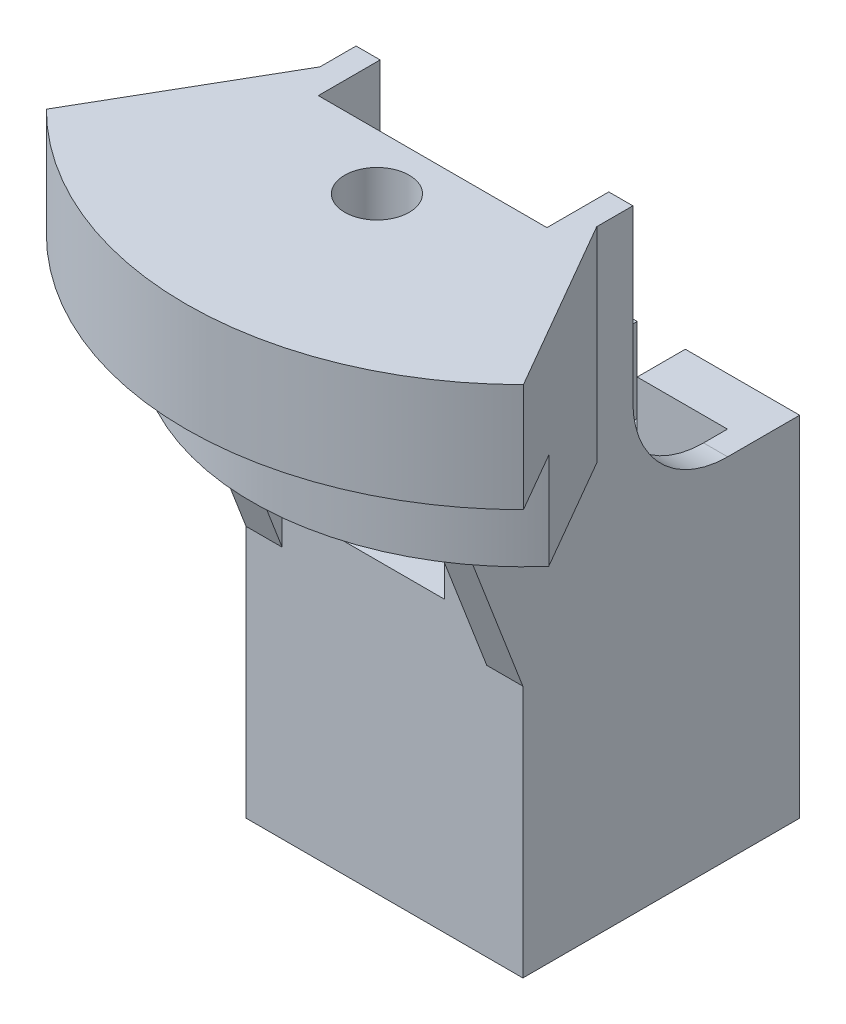
from build123d import *

# Parameters (mm, degrees)
SKETCH1_W                = 29.21
SKETCH1_H                = 29.21
BOSS_EXTRUDE1_DEPTH      = 41.91
SKETCH2_W                = 14.732
SKETCH2_H                = 14.732
CUT_EXTRUDE1_DEPTH       = 8.255
SKETCH3_W                = 24.13
SKETCH3_H                = 19.05
CUT_EXTRUDE2_DEPTH       = 33.655
SKETCH6_W                = 4.699
SKETCH6_H                = 4.445
CUT_EXTRUDE3_DEPTH       = 4.445
BOSS_EXTRUDE2_DEPTH      = 27.94
FILLET1_R                = 10
CHAMFER2_SIZE            = 5.08
CUT_EXTRUDE4_DEPTH       = 27.94
CUT_EXTRUDE5_DEPTH       = 16.51
BOSS_EXTRUDE3_DEPTH      = 10.16
M6_CLEARANCE_HOLE1_D     = 6.8032
M6_CLEARANCE_HOLE1_DEPTH = 32.5000112
M6_CLEARANCE_HOLE1_TIP   = 2.043887482
SKETCH18_W               = 12.7
SKETCH18_H               = 16.067158518
CUT_EXTRUDE9_DEPTH       = 12.7
BOSS_EXTRUDE4_DEPTH      = 3.81
SKETCH19_W               = 5.08
SKETCH19_H               = 5.08
CUT_EXTRUDE10_DEPTH      = 8.89


with BuildPart() as part:
    # Sketch1 → Boss-Extrude1 (new body)
    with BuildSketch(Plane(origin=(0, 0, 0), x_dir=(1, 0, 0), z_dir=(0, 1, 0))):
        Rectangle(SKETCH1_W, SKETCH1_H)
    extrude(amount=BOSS_EXTRUDE1_DEPTH)

    # Sketch2 → Cut-Extrude1 (cut)
    with BuildSketch(Plane.XZ):
        Rectangle(SKETCH2_W, SKETCH2_H)
    extrude(amount=-CUT_EXTRUDE1_DEPTH, mode=Mode.SUBTRACT)

    # Sketch3 → Cut-Extrude2 (cut)
    with BuildSketch(Plane.XZ.offset(-8.255)):
        Rectangle(SKETCH3_W, SKETCH3_H)
    extrude(amount=-CUT_EXTRUDE2_DEPTH, mode=Mode.SUBTRACT)

    # Sketch6 → Cut-Extrude3 (cut)
    with BuildSketch(Plane(origin=(0, 8.255, 0), x_dir=(1, 0, 0), z_dir=(0, 1, 0))):
        with Locations((-9.7155, 0)):
            Rectangle(SKETCH6_W, SKETCH6_H)
    cut_extrude3 = extrude(amount=-CUT_EXTRUDE3_DEPTH, mode=Mode.SUBTRACT)

    # Mirror1: Cut-Extrude3 across plane
    add(cut_extrude3.mirror(Plane(origin=(0, 0, 0), x_dir=(0, 0, 1), z_dir=(1, 0, 0))), mode=Mode.SUBTRACT)

    # Sketch7 → Boss-Extrude2 (add)
    with BuildSketch(Plane(origin=(0, 41.91, 0), x_dir=(1, 0, 0), z_dir=(0, 1, 0))):
        with BuildLine():
            Line((-14.605, -2.997916359), (-35.433403696, -2.997916359))
            ThreePointArc((-35.433403696, -2.997916359), (0, -35.56), (35.433403696, -2.997916359))
            Line((35.433403696, -2.997916359), (14.605, -2.997916359))
            Line((14.605, -2.997916359), (14.605, -14.605))
            Line((14.605, -14.605), (-14.605, -14.605))
            Line((-14.605, -14.605), (-14.605, -2.997916359))
        make_face()
        Polygon((-12.065, -2.997916359), (-14.605, -2.997916359), (-14.605, -14.605), (14.605, -14.605), (14.605, -2.997916359), (12.065, -2.997916359), (12.065, -9.525), (-12.065, -9.525), align=None)
    extrude(amount=BOSS_EXTRUDE2_DEPTH)

    # Fillet1
    fillet1_edges = [part.edges().sort_by_distance(p)[0] for p in [
        (-13.335, 41.91, 2.997916359),
        (13.335, 41.91, 2.997916359),
    ]]
    fillet(fillet1_edges, radius=FILLET1_R)

    # Chamfer2
    chamfer2_edges = [part.edges().sort_by_distance(p)[0] for p in [
        (0, 0, 14.605),
        (-14.605, 0, 0),
        (0, 0, -14.605),
        (14.605, 0, 0),
    ]]
    chamfer(chamfer2_edges, length=CHAMFER2_SIZE)

    # Sketch8 → Cut-Extrude4 (cut)
    with BuildSketch(Plane(origin=(0, 69.85, 0), x_dir=(1, 0, 0), z_dir=(0, 1, 0))):
        with BuildLine():
            Line((-14.605, -2.997916359), (-35.433403696, -2.997916359))
            ThreePointArc((-35.433403696, -2.997916359), (-32.258645828, -14.963066843), (-25.174526181, -25.114872716))
            Line((-25.174526181, -25.114872716), (-14.605, -6.807916359))
            Line((-14.605, -6.807916359), (-14.605, -2.997916359))
        make_face()
    cut_extrude4 = extrude(amount=-CUT_EXTRUDE4_DEPTH, mode=Mode.SUBTRACT)

    # Mirror2: Cut-Extrude4 across plane
    add(cut_extrude4.mirror(Plane(origin=(0, 0, 0), x_dir=(0, 0, 1), z_dir=(1, 0, 0))), mode=Mode.SUBTRACT)

    # Sketch9 → Cut-Extrude5 (cut)
    with BuildSketch(Plane.XZ.offset(-41.91)):
        with BuildLine():
            Line((-14.605, 6.807916359), (-14.605, 14.605))
            Line((-14.605, 14.605), (14.605, 14.605))
            Line((14.605, 14.605), (14.605, 6.807916359))
            Line((14.605, 6.807916359), (25.174526181, 25.114872716))
            ThreePointArc((25.174526181, 25.114872716), (0, 35.56), (-25.174526181, 25.114872716))
            Line((-25.174526181, 25.114872716), (-14.605, 6.807916359))
        make_face()
    extrude(amount=-CUT_EXTRUDE5_DEPTH, mode=Mode.SUBTRACT)

    # Sketch11 → Boss-Extrude3 (add)
    with BuildSketch(Plane(origin=(0, 58.42, 0), x_dir=(-1, 0, 0), z_dir=(0, -1, 0))):
        with BuildLine():
            Line((14.605, -6.807916359), (14.605, -14.605))
            Line((14.605, -14.605), (-14.605, -14.605))
            Line((-14.605, -14.605), (-14.605, -6.807916359))
            Line((-14.605, -6.807916359), (-21.525014254, -18.793732635))
            ThreePointArc((-21.525014254, -18.793732635), (0, -28.575), (21.525014254, -18.793732635))
            Line((21.525014254, -18.793732635), (14.605, -6.807916359))
        make_face()
    extrude(amount=BOSS_EXTRUDE3_DEPTH)

    # M6 Clearance Hole1
    with Locations(Plane(origin=(0, 69.85, 0), x_dir=(1, 0, 0), z_dir=(0, 1, 0))):
        with Locations((0, -15.399579259)):
            Hole(M6_CLEARANCE_HOLE1_D / 2, depth=M6_CLEARANCE_HOLE1_DEPTH)
            with Locations((0, 0, -(M6_CLEARANCE_HOLE1_DEPTH + M6_CLEARANCE_HOLE1_TIP / 2))):  # 118° drill point
                Cone(0, M6_CLEARANCE_HOLE1_D / 2, M6_CLEARANCE_HOLE1_TIP, mode=Mode.SUBTRACT)

    # Sketch18 → Cut-Extrude9 (cut)
    with BuildSketch(Plane.XZ.offset(-48.26)):
        with Locations((0, 15.399579259)):
            Rectangle(SKETCH18_W, SKETCH18_H)
    extrude(amount=CUT_EXTRUDE9_DEPTH, mode=Mode.SUBTRACT)

    # Sketch14 → Boss-Extrude4 (add)
    with BuildSketch(Plane.ZY.offset(14.605)):
        Polygon((14.605, 48.26), (20.955, 48.26), (14.605, 31.75), align=None)
    boss_extrude4 = extrude(amount=-BOSS_EXTRUDE4_DEPTH)

    # Mirror3: Boss-Extrude4 across plane
    add(boss_extrude4.mirror(Plane(origin=(0, 0, 0), x_dir=(0, 0, 1), z_dir=(1, 0, 0))))

    # Sketch19 → Cut-Extrude10 (cut)
    with BuildSketch(Plane(origin=(0, 41.91, 0), x_dir=(1, 0, 0), z_dir=(0, 1, 0))):
        with Locations((0, 12.065)):
            Rectangle(SKETCH19_W, SKETCH19_H)
    extrude(amount=-CUT_EXTRUDE10_DEPTH, mode=Mode.SUBTRACT)


solid = part.part
